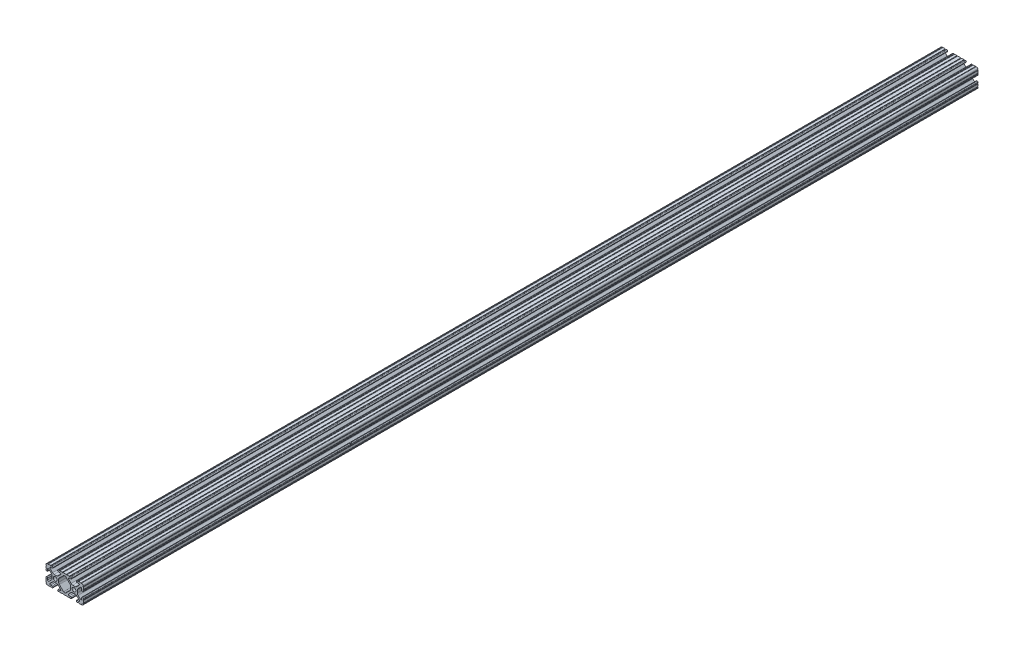
from build123d import *

# Parameters (mm, degrees)
SKETCH1_R               = 2.6035
BOSS_EXTRUDE1_DEPTH     = 609.6
SKETCH2_R               = 3.5
CUT_EXTRUDE1_DEPTH      = 9.191498123
CUT_EXTRUDE1_DEPTH_BACK = 43.608501877


with BuildPart() as part:
    # Sketch1 → Boss-Extrude1 (new body, symmetric)
    with BuildSketch(Plane.XY):
        with BuildLine():
            Line((18.01710265, 12.7), (16.98745015, 12.7))
            ThreePointArc((16.98745015, 12.7), (16.245730386, 12.392769614), (15.9385, 11.65104985))
            Line((15.9385, 11.65104985), (15.9385, 11.53922))
            ThreePointArc((15.9385, 11.53922), (16.245750844, 10.797450844), (16.98752, 10.4902))
            Line((16.98752, 10.4902), (19.116384363, 10.4902))
            ThreePointArc((19.116384363, 10.4902), (20.052502933, 9.869096983), (19.844087081, 8.765172272))
            Line((19.844087081, 8.765172272), (16.618993479, 5.455112286))
            ThreePointArc((16.618993479, 5.455112286), (15.578994274, 4.745442459), (14.344932584, 4.4958))
            Line((14.344932584, 4.4958), (11.083317835, 4.4958))
            ThreePointArc((11.083317835, 4.4958), (9.854330953, 4.743306833), (8.816955189, 5.447238587))
            Line((8.816955189, 5.447238587), (5.564154119, 8.762652677))
            ThreePointArc((5.564154119, 8.762652677), (5.352591412, 9.867473037), (6.289393385, 10.4902))
            Line((6.289393385, 10.4902), (8.41248, 10.4902))
            ThreePointArc((8.41248, 10.4902), (9.154249156, 10.797450844), (9.4615, 11.53922))
            Line((9.4615, 11.53922), (9.4615, 11.65104985))
            ThreePointArc((9.4615, 11.65104985), (9.154269614, 12.392769614), (8.41254985, 12.7))
            Line((8.41254985, 12.7), (7.38288465, 12.7))
            ThreePointArc((7.38288465, 12.7), (6.87488465, 12.192), (6.36688465, 12.7))
            Line((6.36688465, 12.7), (3.14958095, 12.7))
            ThreePointArc((3.14958095, 12.7), (2.64158095, 12.192), (2.13358095, 12.7))
            Line((2.13358095, 12.7), (-2.13358095, 12.7))
            ThreePointArc((-2.13358095, 12.7), (-2.64158095, 12.192), (-3.14958095, 12.7))
            Line((-3.14958095, 12.7), (-6.36689735, 12.7))
            ThreePointArc((-6.36689735, 12.7), (-6.87489735, 12.192), (-7.38289735, 12.7))
            Line((-7.38289735, 12.7), (-8.41254985, 12.7))
            ThreePointArc((-8.41254985, 12.7), (-9.154269614, 12.392769614), (-9.4615, 11.65104985))
            Line((-9.4615, 11.65104985), (-9.4615, 11.53922))
            ThreePointArc((-9.4615, 11.53922), (-9.154249156, 10.797450844), (-8.41248, 10.4902))
            Line((-8.41248, 10.4902), (-6.283641037, 10.4902))
            ThreePointArc((-6.283641037, 10.4902), (-5.297291557, 9.829633109), (-5.532576693, 8.666071843))
            Line((-5.532576693, 8.666071843), (-8.809985098, 5.416263103))
            ThreePointArc((-8.809985098, 5.416263103), (-9.836720513, 4.734920264), (-11.045536121, 4.4958))
            Line((-11.045536121, 4.4958), (-14.354463879, 4.4958))
            ThreePointArc((-14.354463879, 4.4958), (-15.563279487, 4.734920264), (-16.590014902, 5.416263103))
            Line((-16.590014902, 5.416263103), (-19.867423307, 8.666071843))
            ThreePointArc((-19.867423307, 8.666071843), (-20.102708443, 9.829633109), (-19.116358963, 10.4902))
            Line((-19.116358963, 10.4902), (-16.98752, 10.4902))
            ThreePointArc((-16.98752, 10.4902), (-16.245750844, 10.797450844), (-15.9385, 11.53922))
            Line((-15.9385, 11.53922), (-15.9385, 11.65104985))
            ThreePointArc((-15.9385, 11.65104985), (-16.245730386, 12.392769614), (-16.98745015, 12.7))
            Line((-16.98745015, 12.7), (-18.01711535, 12.7))
            ThreePointArc((-18.01711535, 12.7), (-18.52511535, 12.192), (-19.03311535, 12.7))
            Line((-19.03311535, 12.7), (-22.2504, 12.7))
            ThreePointArc((-22.2504, 12.7), (-22.758323491, 12.192000006), (-23.266399977, 12.699846982))
            ThreePointArc((-23.266399977, 12.699846982), (-24.782522516, 12.082522516), (-25.399846982, 10.566399977))
            ThreePointArc((-25.399846982, 10.566399977), (-24.892000006, 10.058323491), (-25.4, 9.5504))
            Line((-25.4, 9.5504), (-25.4, 6.3330836))
            ThreePointArc((-25.4, 6.3330836), (-24.892, 5.8250836), (-25.4, 5.3170836))
            Line((-25.4, 5.3170836), (-25.4, 4.237520184))
            ThreePointArc((-25.4, 4.237520184), (-25.107393763, 3.531106237), (-24.400979816, 3.2385))
            Line((-24.400979816, 3.2385), (-24.23922, 3.2385))
            ThreePointArc((-24.23922, 3.2385), (-23.497450844, 3.545750844), (-23.1902, 4.28752))
            Line((-23.1902, 4.28752), (-23.1902, 6.334741132))
            ThreePointArc((-23.1902, 6.334741132), (-22.556026952, 7.286023527), (-21.434002553, 7.066535717))
            Line((-21.434002553, 7.066535717), (-18.147950853, 3.808156468))
            ThreePointArc((-18.147950853, 3.808156468), (-17.452759693, 2.774838327), (-17.208501877, 1.553619571))
            Line((-17.208501877, 1.553619571), (-17.208501877, -1.695179196))
            ThreePointArc((-17.208501877, -1.695179196), (-17.450738657, -2.911536421), (-18.140486065, -3.942289578))
            Line((-18.140486065, -3.942289578), (-21.431579576, -7.227386226))
            ThreePointArc((-21.431579576, -7.227386226), (-22.55444896, -7.449940594), (-23.1902, -6.498002195))
            Line((-23.1902, -6.498002195), (-23.1902, -4.28752))
            ThreePointArc((-23.1902, -4.28752), (-23.497450844, -3.545750844), (-24.23922, -3.2385))
            Line((-24.23922, -3.2385), (-24.35098, -3.2385))
            ThreePointArc((-24.35098, -3.2385), (-25.092749156, -3.545750844), (-25.4, -4.28752))
            Line((-25.4, -4.28752), (-25.4, -5.3171344))
            ThreePointArc((-25.4, -5.3171344), (-24.892, -5.8251344), (-25.4, -6.3331344))
            Line((-25.4, -6.3331344), (-25.4, -9.5504))
            ThreePointArc((-25.4, -9.5504), (-24.892000006, -10.058323491), (-25.399846982, -10.566399977))
            ThreePointArc((-25.399846982, -10.566399977), (-24.782522516, -12.082522516), (-23.266399977, -12.699846982))
            ThreePointArc((-23.266399977, -12.699846982), (-22.758323491, -12.192000006), (-22.2504, -12.7))
            Line((-22.2504, -12.7), (-19.03308995, -12.7))
            ThreePointArc((-19.03308995, -12.7), (-18.52508995, -12.192), (-18.01708995, -12.7))
            Line((-18.01708995, -12.7), (-16.9874692, -12.7))
            ThreePointArc((-16.9874692, -12.7), (-16.245700044, -12.392749156), (-15.9384492, -11.65098))
            Line((-15.9384492, -11.65098), (-15.9384492, -11.53922))
            ThreePointArc((-15.9384492, -11.53922), (-16.245700044, -10.797450844), (-16.9874692, -10.4902))
            Line((-16.9874692, -10.4902), (-19.116358963, -10.4902))
            ThreePointArc((-19.116358963, -10.4902), (-20.055197748, -9.862578342), (-19.834124023, -8.755124678))
            Line((-19.834124023, -8.755124678), (-16.49660751, -5.423689618))
            ThreePointArc((-16.49660751, -5.423689618), (-15.467274017, -4.736928798), (-14.253591699, -4.4958))
            Line((-14.253591699, -4.4958), (-11.146408301, -4.4958))
            ThreePointArc((-11.146408301, -4.4958), (-9.932725983, -4.736928798), (-8.90339249, -5.423689618))
            Line((-8.90339249, -5.423689618), (-5.565875977, -8.755124678))
            ThreePointArc((-5.565875977, -8.755124678), (-5.344802252, -9.862578342), (-6.283641037, -10.4902))
            Line((-6.283641037, -10.4902), (-8.4125308, -10.4902))
            ThreePointArc((-8.4125308, -10.4902), (-9.154299956, -10.797450844), (-9.4615508, -11.53922))
            Line((-9.4615508, -11.53922), (-9.4615508, -11.65098))
            ThreePointArc((-9.4615508, -11.65098), (-9.154299956, -12.392749156), (-8.4125308, -12.7))
            Line((-8.4125308, -12.7), (-7.38287195, -12.7))
            ThreePointArc((-7.38287195, -12.7), (-6.87487195, -12.192), (-6.36687195, -12.7))
            Line((-6.36687195, -12.7), (-3.14960635, -12.7))
            ThreePointArc((-3.14960635, -12.7), (-2.64160635, -12.192), (-2.13360635, -12.7))
            Line((-2.13360635, -12.7), (2.13360635, -12.7))
            ThreePointArc((2.13360635, -12.7), (2.64159365, -12.1920127), (3.14958095, -12.7))
            Line((3.14958095, -12.7), (6.36691005, -12.7))
            ThreePointArc((6.36691005, -12.7), (6.87491005, -12.192), (7.38291005, -12.7))
            Line((7.38291005, -12.7), (8.4125308, -12.7))
            ThreePointArc((8.4125308, -12.7), (9.154299956, -12.392749156), (9.4615508, -11.65098))
            Line((9.4615508, -11.65098), (9.4615508, -11.53922))
            ThreePointArc((9.4615508, -11.53922), (9.154299956, -10.797450844), (8.4125308, -10.4902))
            Line((8.4125308, -10.4902), (6.289393385, -10.4902))
            ThreePointArc((6.289393385, -10.4902), (5.231590322, -9.783049717), (5.480677245, -8.535265862))
            Line((5.480677245, -8.535265862), (8.597933595, -5.423689618))
            ThreePointArc((8.597933595, -5.423689618), (9.627267088, -4.736928798), (10.840949406, -4.4958))
            Line((10.840949406, -4.4958), (14.102564155, -4.4958))
            ThreePointArc((14.102564155, -4.4958), (15.215927525, -4.697410182), (16.187895372, -5.276636531))
            Line((16.187895372, -5.276636531), (19.868247549, -8.482246082))
            ThreePointArc((19.868247549, -8.482246082), (20.188435806, -9.746879864), (19.116384363, -10.4902))
            Line((19.116384363, -10.4902), (16.9874692, -10.4902))
            ThreePointArc((16.9874692, -10.4902), (16.245700044, -10.797450844), (15.9384492, -11.53922))
            Line((15.9384492, -11.53922), (15.9384492, -11.65098))
            ThreePointArc((15.9384492, -11.65098), (16.245700044, -12.392749156), (16.9874692, -12.7))
            Line((16.9874692, -12.7), (18.01710265, -12.7))
            ThreePointArc((18.01710265, -12.7), (18.52510265, -12.192), (19.03310265, -12.7))
            Line((19.03310265, -12.7), (22.2504, -12.7))
            ThreePointArc((22.2504, -12.7), (22.758323491, -12.192000006), (23.266399977, -12.699846982))
            ThreePointArc((23.266399977, -12.699846982), (24.782522516, -12.082522516), (25.399846982, -10.566399977))
            ThreePointArc((25.399846982, -10.566399977), (24.892000006, -10.058323492), (25.4, -9.550400001))
            Line((25.4, -9.550400001), (25.4, -6.333083592))
            ThreePointArc((25.4, -6.333083592), (24.892000001, -5.825083593), (25.4, -5.317083593))
            Line((25.4, -5.317083593), (25.4, -4.237520184))
            ThreePointArc((25.4, -4.237520184), (25.107393763, -3.531106237), (24.400979816, -3.2385))
            Line((24.400979816, -3.2385), (24.189220184, -3.2385))
            ThreePointArc((24.189220184, -3.2385), (23.482806237, -3.531106237), (23.1902, -4.237520184))
            Line((23.1902, -4.237520184), (23.1902, -6.155876159))
            ThreePointArc((23.1902, -6.155876159), (22.62232736, -7.038258539), (21.583974541, -6.886926384))
            Line((21.583974541, -6.886926384), (18.29817066, -4.024970844))
            ThreePointArc((18.29817066, -4.024970844), (17.493730985, -2.946044689), (17.208501877, -1.630807374))
            Line((17.208501877, -1.630807374), (17.208501877, 1.630807374))
            ThreePointArc((17.208501877, 1.630807374), (17.442348332, 2.82673414), (18.109440981, 3.846495088))
            Line((18.109440981, 3.846495088), (21.526346532, 7.353420386))
            ThreePointArc((21.526346532, 7.353420386), (22.585896263, 7.574939077), (23.1902, 6.676867167))
            Line((23.1902, 6.676867167), (23.1902, 4.237520184))
            ThreePointArc((23.1902, 4.237520184), (23.482806237, 3.531106237), (24.189220184, 3.2385))
            Line((24.189220184, 3.2385), (24.400979816, 3.2385))
            ThreePointArc((24.400979816, 3.2385), (25.107393763, 3.531106237), (25.4, 4.237520184))
            Line((25.4, 4.237520184), (25.4, 5.3170836))
            ThreePointArc((25.4, 5.3170836), (24.891949193, 5.825134407), (25.4, 6.333185215))
            Line((25.4, 6.333185215), (25.4, 9.550400015))
            ThreePointArc((25.4, 9.550400015), (24.892000013, 10.058323498), (25.399846982, 10.566399977))
            ThreePointArc((25.399846982, 10.566399977), (24.782522516, 12.082522516), (23.266399977, 12.699846982))
            ThreePointArc((23.266399977, 12.699846982), (22.758323491, 12.192000006), (22.2504, 12.7))
            Line((22.2504, 12.7), (19.03310265, 12.7))
            ThreePointArc((19.03310265, 12.7), (18.52510265, 12.192), (18.01710265, 12.7))
        make_face()
        with Locations((-12.7, 0)):
            Circle(SKETCH1_R, mode=Mode.SUBTRACT)
        with Locations((12.7, 0)):
            Circle(SKETCH1_R, mode=Mode.SUBTRACT)
        with BuildLine():
            Line((-7.259513935, -3.869413038), (-1.545748891, -9.572766749))
            ThreePointArc((-1.545748891, -9.572766749), (-1.035199478, -9.913400116), (-0.433213048, -10.033))
            Line((-0.433213048, -10.033), (0.433213048, -10.033))
            ThreePointArc((0.433213048, -10.033), (1.035199478, -9.913400116), (1.545748891, -9.572766749))
            Line((1.545748891, -9.572766749), (7.259513935, -3.869413038))
            ThreePointArc((7.259513935, -3.869413038), (7.949261343, -2.838659881), (8.191498123, -1.622302656))
            Line((8.191498123, -1.622302656), (8.191498123, 1.622302656))
            ThreePointArc((8.191498123, 1.622302656), (7.955573352, 2.823327967), (7.282860769, 3.845864069))
            Line((7.282860769, 3.845864069), (1.675572808, 9.561086461))
            ThreePointArc((1.675572808, 9.561086461), (1.161034429, 9.910236611), (0.551456936, 10.033))
            Line((0.551456936, 10.033), (-0.395199982, 10.033))
            ThreePointArc((-0.395199982, 10.033), (-0.994772524, 9.914396349), (-1.50403329, 9.576450301))
            Line((-1.50403329, 9.576450301), (-7.252049147, 3.876839553))
            ThreePointArc((-7.252049147, 3.876839553), (-7.947240307, 2.843521412), (-8.191498123, 1.622302656))
            Line((-8.191498123, 1.622302656), (-8.191498123, -1.622302656))
            ThreePointArc((-8.191498123, -1.622302656), (-7.949261343, -2.838659881), (-7.259513935, -3.869413038))
        make_face(mode=Mode.SUBTRACT)
    extrude(amount=BOSS_EXTRUDE1_DEPTH, both=True)

    # Sketch2 → Cut-Extrude1 (cut, two sides)
    with BuildSketch(Plane(origin=(17.208501877, 0, 0), x_dir=(0, 0, -1), z_dir=(1, 0, 0))) as cut_extrude1_sk:
        with Locations((244.47, 0)):
            Circle(SKETCH2_R)
        with Locations((-244.47, 0)):
            Circle(SKETCH2_R)
        with Locations((396.87, 0)):
            Circle(SKETCH2_R)
        with Locations((-396.87, 0)):
            Circle(SKETCH2_R)
    extrude(amount=CUT_EXTRUDE1_DEPTH, mode=Mode.SUBTRACT)
    extrude(cut_extrude1_sk.sketch, amount=-CUT_EXTRUDE1_DEPTH_BACK, mode=Mode.SUBTRACT)


solid = part.part
